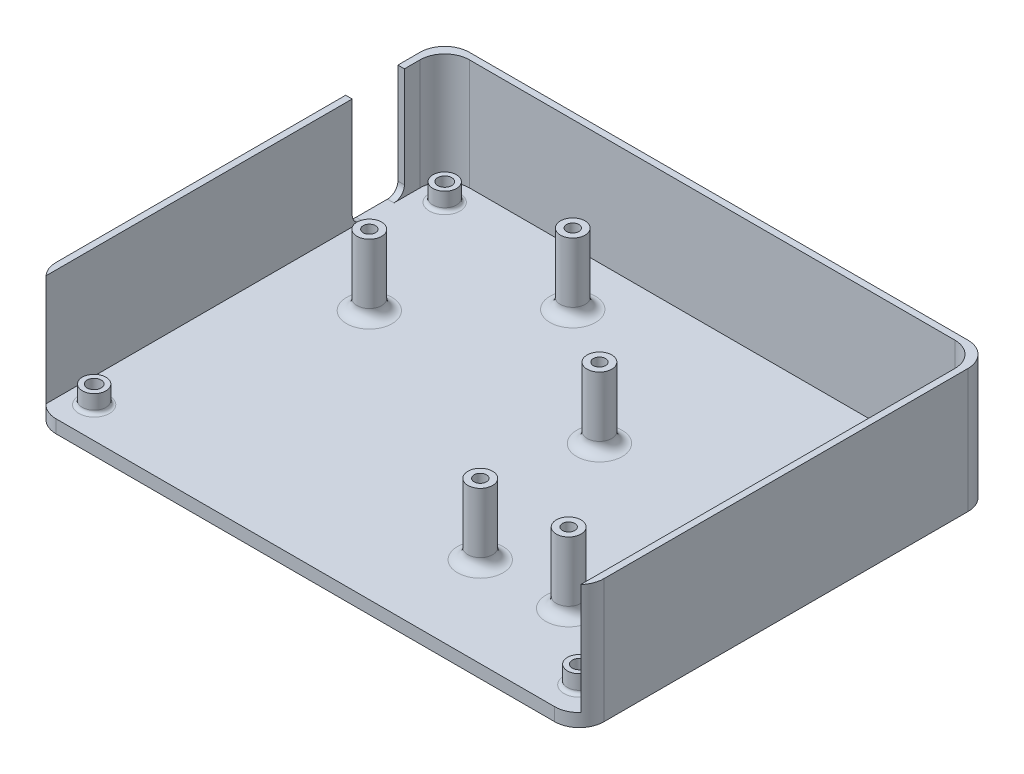
from build123d import *

# Parameters (mm, degrees)
BOSS_EXTRUDE12_DEPTH = 3.175
BOSS_EXTRUDE13_DEPTH = 30.1625
SKETCH1_25_R         = 2.875
SKETCH1_25_R_2       = 1.7
BOSS_EXTRUDE15_DEPTH = 7.525
SKETCH1_27_R         = 1.7
CUT_EXTRUDE3_DEPTH   = 28.575
CHAMFER2_SIZE        = 1.45
FILLET3_R            = 6
FILLET4_R            = 0.85
FILLET5_R            = 0.85
SKETCH2_W            = 12.7
SKETCH2_H            = 26.9875
CUT_EXTRUDE4_DEPTH   = 2.54
FILLET6_R            = 2.54
SKETCH1_30_R         = 3
SKETCH1_30_R_2       = 1.5
BOSS_EXTRUDE16_DEPTH = 20.32
FILLET7_R            = 2.54


with BuildPart() as part:
    # Sketch1 → Boss-Extrude12 (new body)
    with BuildSketch(Plane(origin=(0, 0, 0), x_dir=(1, 0, 0), z_dir=(0, 1, 0))):
        with BuildLine():
            Line((-66.858315384, -50.276221126), (-65.270815384, -50.276221126))
            Line((-65.270815384, -50.276221126), (64.85543465, -50.276221126))
            Line((64.85543465, -50.276221126), (66.44293465, -50.276221126))
            Line((66.44293465, -50.276221126), (66.44293465, 44.266274766))
            ThreePointArc((66.44293465, 44.266274766), (64.685575338, 48.508915454), (60.44293465, 50.266274766))
            Line((60.44293465, 50.266274766), (-60.858315384, 50.266274766))
            ThreePointArc((-60.858315384, 50.266274766), (-65.100956071, 48.508915454), (-66.858315384, 44.266274766))
            Line((-66.858315384, 44.266274766), (-66.858315384, -50.276221126))
        make_face()
    extrude(amount=BOSS_EXTRUDE12_DEPTH)

    # Sketch1_23 → Boss-Extrude13 (add)
    with BuildSketch(Plane(origin=(0, 0, 0), x_dir=(1, 0, 0), z_dir=(0, 1, 0))):
        with BuildLine():
            Line((-66.858315384, 44.266274766), (-66.858315384, -50.276221126))
            Line((-66.858315384, -50.276221126), (-65.270815384, -50.276221126))
            Line((-65.270815384, -50.276221126), (-65.270815384, 42.678774766))
            ThreePointArc((-65.270815384, 42.678774766), (-63.513456071, 46.921415454), (-59.270815384, 48.678774766))
            Line((-59.270815384, 48.678774766), (58.85543465, 48.678774766))
            ThreePointArc((58.85543465, 48.678774766), (63.098075338, 46.921415454), (64.85543465, 42.678774766))
            Line((64.85543465, 42.678774766), (64.85543465, -50.276221126))
            Line((64.85543465, -50.276221126), (66.44293465, -50.276221126))
            Line((66.44293465, -50.276221126), (66.44293465, 44.266274766))
            ThreePointArc((66.44293465, 44.266274766), (64.685575338, 48.508915454), (60.44293465, 50.266274766))
            Line((60.44293465, 50.266274766), (-60.858315384, 50.266274766))
            ThreePointArc((-60.858315384, 50.266274766), (-65.100956071, 48.508915454), (-66.858315384, 44.266274766))
        make_face()
    extrude(amount=BOSS_EXTRUDE13_DEPTH)

    # Sketch1_25 → Boss-Extrude15 (add)
    # profile 1 of 4: a face of its own
    with BuildSketch(Plane(origin=(0, 0, 0), x_dir=(1, 0, 0), z_dir=(0, 1, 0))):
        with Locations((-59.238315384, 42.646274766)):
            Circle(SKETCH1_25_R)
        with Locations((-59.238315384, 42.646274766)):
            Circle(SKETCH1_25_R_2, mode=Mode.SUBTRACT)
    # profile 2 of 4: a face of its own
    with BuildSketch(Plane(origin=(0, 0, 0), x_dir=(1, 0, 0), z_dir=(0, 1, 0))):
        with Locations((58.82293465, 42.646274766)):
            Circle(SKETCH1_25_R)
        with Locations((58.82293465, 42.646274766)):
            Circle(SKETCH1_25_R_2, mode=Mode.SUBTRACT)
    # profile 3 of 4: a face of its own
    with BuildSketch(Plane(origin=(0, 0, 0), x_dir=(1, 0, 0), z_dir=(0, 1, 0))):
        with Locations((-59.238315384, -42.656221126)):
            Circle(SKETCH1_25_R)
        with Locations((-59.238315384, -42.656221126)):
            Circle(SKETCH1_25_R_2, mode=Mode.SUBTRACT)
    # profile 4 of 4: a face of its own
    with BuildSketch(Plane(origin=(0, 0, 0), x_dir=(1, 0, 0), z_dir=(0, 1, 0))):
        with Locations((58.82293465, -42.656221126)):
            Circle(SKETCH1_25_R)
        with Locations((58.82293465, -42.656221126)):
            Circle(SKETCH1_25_R_2, mode=Mode.SUBTRACT)
    extrude(amount=BOSS_EXTRUDE15_DEPTH)

    # Sketch1_27 → Cut-Extrude3 (cut)
    with BuildSketch(Plane(origin=(0, 0, 0), x_dir=(1, 0, 0), z_dir=(0, 1, 0))):
        with Locations((-59.238315384, 42.646274766)):
            Circle(SKETCH1_27_R)
        with Locations((58.82293465, 42.646274766)):
            Circle(SKETCH1_27_R)
        with Locations((-59.238315384, -42.656221126)):
            Circle(SKETCH1_27_R)
        with Locations((58.82293465, -42.656221126)):
            Circle(SKETCH1_27_R)
    extrude(amount=CUT_EXTRUDE3_DEPTH, mode=Mode.SUBTRACT)

    # Chamfer2
    chamfer2_edges = [part.edges().sort_by_distance(p)[0] for p in [
        (57.12293465, 0, 42.656221126),
        (57.12293465, 0, -42.646274766),
        (-60.938315384, 0, 42.656221126),
        (-60.938315384, 0, -42.646274766),
    ]]
    chamfer(chamfer2_edges, length=CHAMFER2_SIZE)

    # Fillet3
    fillet3_edges = [part.edges().sort_by_distance(p)[0] for p in [
        (66.44293465, 15.08125, 50.276221126),
        (-66.858315384, 15.08125, 50.276221126),
    ]]
    fillet(fillet3_edges, radius=FILLET3_R)

    # Fillet4
    fillet4_edges = [part.edges().sort_by_distance(p)[0] for p in [
        (-62.113315384, 3.175, -42.646274766),
    ]]
    fillet(fillet4_edges, radius=FILLET4_R)

    # Fillet5
    fillet5_edges = [part.edges().sort_by_distance(p)[0] for p in [
        (-62.113315384, 3.175, 42.656221126),
        (55.94793465, 3.175, 42.656221126),
        (55.94793465, 3.175, -42.646274766),
    ]]
    fillet(fillet5_edges, radius=FILLET5_R)

    # Sketch2 → Cut-Extrude4 (cut)
    with BuildSketch(Plane(origin=(-65.270815384, 0, 0), x_dir=(0, 0, -1), z_dir=(1, 0, 0))):
        with Locations((32.519846941, 16.66875)):
            Rectangle(SKETCH2_W, SKETCH2_H)
    extrude(amount=-CUT_EXTRUDE4_DEPTH, mode=Mode.SUBTRACT)

    # Fillet6
    fillet6_edges = [part.edges().sort_by_distance(p)[0] for p in [
        (-66.064565384, 3.175, -38.869846941),
        (-66.064565384, 3.175, -26.169846941),
    ]]
    fillet(fillet6_edges, radius=FILLET6_R)

    # Sketch1_30 → Boss-Extrude16 (add)
    # profile 1 of 5: a face of its own
    with BuildSketch(Plane(origin=(0, 0, 0), x_dir=(1, 0, 0), z_dir=(0, 1, 0))):
        with Locations((-45.587205324, 10.652944173)):
            Circle(SKETCH1_30_R)
        with Locations((-45.587205324, 10.652944173)):
            Circle(SKETCH1_30_R_2, mode=Mode.SUBTRACT)
    # profile 2 of 5: a face of its own
    with BuildSketch(Plane(origin=(0, 0, 0), x_dir=(1, 0, 0), z_dir=(0, 1, 0))):
        with Locations((-21.087205302, 35.652944211)):
            Circle(SKETCH1_30_R)
        with Locations((-21.087205302, 35.652944211)):
            Circle(SKETCH1_30_R_2, mode=Mode.SUBTRACT)
    # profile 3 of 5: a face of its own
    with BuildSketch(Plane(origin=(0, 0, 0), x_dir=(1, 0, 0), z_dir=(0, 1, 0))):
        with Locations((10.41279469, 10.652944173)):
            Circle(SKETCH1_30_R)
        with Locations((10.41279469, 10.652944173)):
            Circle(SKETCH1_30_R_2, mode=Mode.SUBTRACT)
    # profile 4 of 5: a face of its own
    with BuildSketch(Plane(origin=(0, 0, 0), x_dir=(1, 0, 0), z_dir=(0, 1, 0))):
        with Locations((20.412794756, -28.347055805)):
            Circle(SKETCH1_30_R)
        with Locations((20.412794756, -28.347055805)):
            Circle(SKETCH1_30_R_2, mode=Mode.SUBTRACT)
    # profile 5 of 5: a face of its own
    with BuildSketch(Plane(origin=(0, 0, 0), x_dir=(1, 0, 0), z_dir=(0, 1, 0))):
        with Locations((41.412794666, -27.847055789)):
            Circle(SKETCH1_30_R)
        with Locations((41.412794666, -27.847055789)):
            Circle(SKETCH1_30_R_2, mode=Mode.SUBTRACT)
    extrude(amount=BOSS_EXTRUDE16_DEPTH)

    # Fillet7
    fillet7_edges = [part.edges().sort_by_distance(p)[0] for p in [
        (38.412794666, 3.175, 27.847055789),
        (17.412794756, 3.175, 28.347055805),
        (7.41279469, 3.175, -10.652944173),
        (-24.087205302, 3.175, -35.652944211),
        (-48.587205324, 3.175, -10.652944173),
    ]]
    fillet(fillet7_edges, radius=FILLET7_R)


solid = part.part
